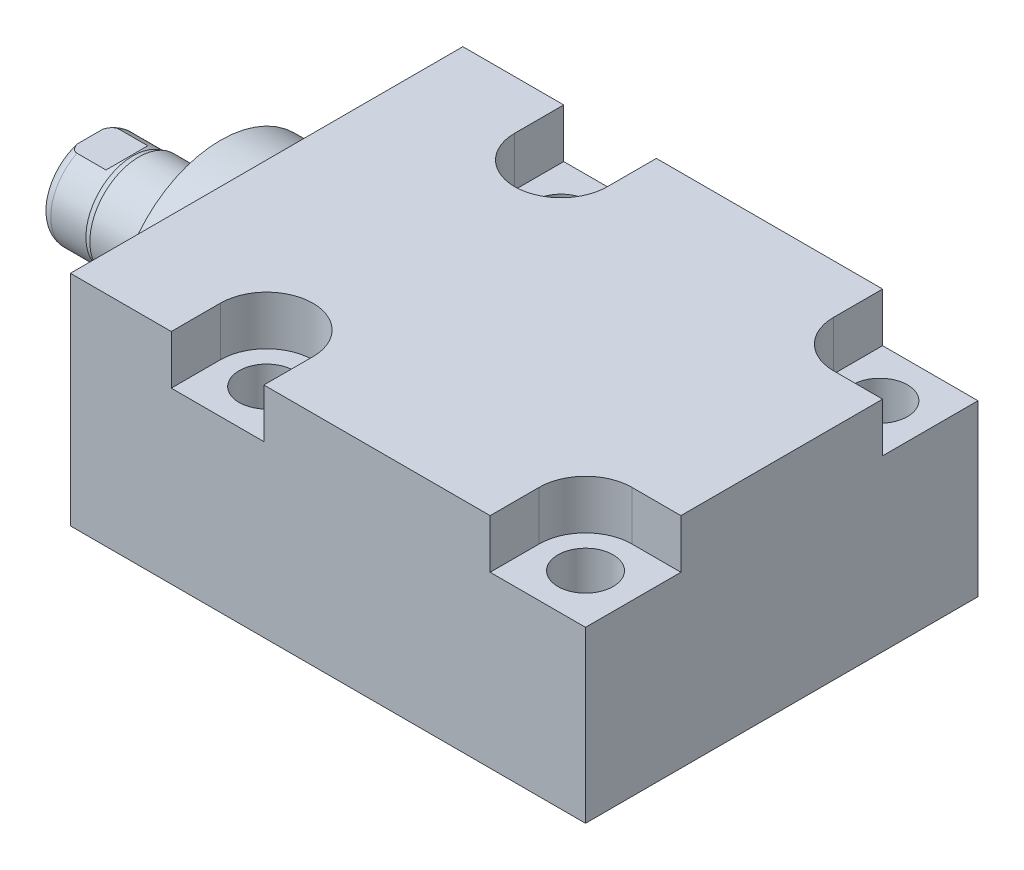
from build123d import *

# Parameters (mm, degrees)
SKETCH1_W          = 50.8
SKETCH1_H          = 28.321
EXTRUDE1_DEPTH     = 66.675
SKETCH5_R          = 13.5001
EXTRUDE2_DEPTH     = 5.969
SKETCH6_W          = 6.35
SKETCH6_H          = 16.891
CUT_EXTRUDE4_DEPTH = 30.48
HOLE2_D            = 7.1374
HOLE2_DEPTH        = 28.321
LPATTERN1_COUNT    = 2
LPATTERN1_PITCH    = 41.275
CUT_EXTRUDE5_DEPTH = 6.35
HOLE3_D            = 2.3876
HOLE3_DEPTH        = 14.224
HOLE3_CBORE_D      = 11.3411
HOLE3_CBORE_DEPTH  = 1.4478
HOLE3_TIP          = 0.717307407
HOLE4_D            = 3.175
HOLE4_DEPTH        = 14.224
HOLE4_TIP          = 0.953866233
SKETCH26_R         = 5.6705
CUT_EXTRUDE6_DEPTH = 1.448
CHAMFER1_SIZE      = 0.635
SKETCH23_R         = 1.4478
LPATTERN3_COUNT    = 2
LPATTERN3_PITCH    = 41.275


with BuildPart() as part:
    # Sketch1 → Extrude1 (new body)
    with BuildSketch(Plane(origin=(0, 0, 0), x_dir=(0, 0, -1), z_dir=(1, 0, 0))):
        with Locations((0, 0.1105)):
            Rectangle(SKETCH1_W, SKETCH1_H)
    extrude(amount=EXTRUDE1_DEPTH)

    # Sketch5 → Extrude2 (add)
    with BuildSketch(Plane.ZY):
        with Locations(Location((0, 0, 0), (0, 0, 180))):  # turned: the seam where the file's is
            Circle(SKETCH5_R)
    extrude(amount=EXTRUDE2_DEPTH)

    # Sketch6 → Revolve1 (revolve)
    with BuildSketch(Plane(origin=(0, 0, 0), x_dir=(0, 0, 1), z_dir=(0, -1, 0))):
        with Locations((-3.175, 14.4145)):
            Rectangle(SKETCH6_W, SKETCH6_H)
    revolve(axis=Axis((5.754582971, 0, 0), (-1, 0, 0)))

    # S2D0001 → Cut-Revolve4 (revolve, cut)
    with BuildSketch(Plane(origin=(-18.511260017, 3.2639, 0), x_dir=(0, 1, 0), z_dir=(0, 0, 1)), mode=Mode.PRIVATE) as cut_revolve4_sk:
        Polygon((-0.7112, 2.786949769), (-0.7112, -11.653260017), (-3.2639, -13.18707692), (-3.2639, 4.348739983), (0.1905, 4.348739983), align=None)
    revolve(cut_revolve4_sk.sketch.rotate(Axis((0, 0, 0), (-1, 0, 0)), 90), axis=Axis((0, 0, 0), (-1, 0, 0)), mode=Mode.SUBTRACT)  # turned: the seam where the file's is

    # Sketch8 → Cut-Revolve5 (revolve, cut)
    with BuildSketch(Plane(origin=(0, 0, 0), x_dir=(0, 0, -1), z_dir=(0, 1, 0)), mode=Mode.PRIVATE) as cut_revolve5_sk:
        with BuildLine():
            Line((-6.35, 16.5354), (-6.096, 17.2974))
            Line((-6.096, 17.2974), (-6.096, 21.844))
            ThreePointArc((-6.096, 21.844), (-5.995678675, 22.387796865), (-5.707922533, 22.86))
            Line((-5.707922533, 22.86), (-6.35, 22.86))
            Line((-6.35, 22.86), (-6.35, 16.5354))
        make_face()
    revolve(cut_revolve5_sk.sketch.rotate(Axis((-12.65936, 0, 0), (-1, 0, 0)), 180), axis=Axis((-12.65936, 0, 0), (-1, 0, 0)), mode=Mode.SUBTRACT)  # turned: the seam where the file's is

    # Sketch12 → Cut-Extrude4 (cut, symmetric)
    with BuildSketch(Plane(origin=(0, 0, 0), x_dir=(0, -1, 0), z_dir=(0, 0, -1))):
        Polygon((5.461, 22.86), (5.461, 18.0848), (6.096, 17.4498), (6.096, 22.86), align=None)
        Polygon((-5.461, 22.86), (-5.461, 18.0848), (-6.096, 17.4498), (-6.096, 22.86), align=None)
    extrude(amount=CUT_EXTRUDE4_DEPTH, both=True, mode=Mode.SUBTRACT)

    # Hole2
    with Locations(Plane(origin=(0, 14.271, 0), x_dir=(-1, 0, 0), z_dir=(0, 1, 0))):
        with Locations((-19.05, -19.05), (-19.05, 19.05)):
            hole2 = Hole(HOLE2_D / 2, depth=HOLE2_DEPTH)

    # LPattern1: Hole2 ×2
    with Locations(*[(i * LPATTERN1_PITCH, 0, 0) for i in range(1, LPATTERN1_COUNT)]):
        add(hole2, mode=Mode.SUBTRACT)

    # Sketch18 → Cut-Extrude5 (cut)
    with BuildSketch(Plane(origin=(0, 14.271, 0), x_dir=(1, 0, 0), z_dir=(0, 1, 0))):
        with BuildLine():
            Line((66.675, -25.4), (54.3306, -25.4))
            Line((54.3306, -25.4), (54.3306, -19.05))
            ThreePointArc((54.3306, -19.05), (56.086319111, -14.811319111), (60.325, -13.0556))
            Line((60.325, -13.0556), (66.675, -13.0556))
            Line((66.675, -13.0556), (66.675, -25.4))
        make_face()
        with BuildLine():
            Line((13.0556, -19.05), (13.0556, -25.4))
            Line((13.0556, -25.4), (25.0444, -25.4))
            Line((25.0444, -25.4), (25.0444, -19.05))
            ThreePointArc((25.0444, -19.05), (19.05, -13.0556), (13.0556, -19.05))
        make_face()
        with BuildLine():
            Line((66.675, 13.0556), (66.675, 25.4))
            Line((66.675, 25.4), (54.3306, 25.4))
            Line((54.3306, 25.4), (54.3306, 19.05))
            ThreePointArc((54.3306, 19.05), (56.086319111, 14.811319111), (60.325, 13.0556))
            Line((60.325, 13.0556), (66.675, 13.0556))
        make_face()
        with BuildLine():
            Line((25.0444, 25.4), (13.0556, 25.4))
            Line((13.0556, 25.4), (13.0556, 19.05))
            ThreePointArc((13.0556, 19.05), (19.05, 13.0556), (25.0444, 19.05))
            Line((25.0444, 19.05), (25.0444, 25.4))
        make_face()
    extrude(amount=-CUT_EXTRUDE5_DEPTH, mode=Mode.SUBTRACT)

    # Hole3
    with Locations(Plane.XZ.offset(14.05)):
        with Locations((12.7, 0)):
            CounterBoreHole(HOLE3_D / 2, HOLE3_CBORE_D / 2, HOLE3_CBORE_DEPTH, depth=HOLE3_DEPTH)
            with Locations((0, 0, -(HOLE3_DEPTH + HOLE3_TIP / 2))):  # 118° drill point
                Cone(0, HOLE3_D / 2, HOLE3_TIP, mode=Mode.SUBTRACT)

    # Hole4
    with Locations(Plane.XZ.offset(14.05)):
        with Locations((55.425, 0)):
            Hole(HOLE4_D / 2, depth=HOLE4_DEPTH)
            with Locations((0, 0, -(HOLE4_DEPTH + HOLE4_TIP / 2))):  # 118° drill point
                Cone(0, HOLE4_D / 2, HOLE4_TIP, mode=Mode.SUBTRACT)

    # Sketch26 → Cut-Extrude6 (cut)
    with BuildSketch(Plane.XZ.offset(14.05)):
        with Locations(Location((53.975, 0, 0), (0, 0, 270))):  # turned: the seam where the file's is
            Circle(SKETCH26_R)
    extrude(amount=-CUT_EXTRUDE6_DEPTH, mode=Mode.SUBTRACT)

    # Chamfer1
    chamfer1_edges = [part.edges().sort_by_distance(p)[0] for p in [
        (13.8938, -12.6022, 0),
        (57.0125, -12.602, 0),
    ]]
    chamfer(chamfer1_edges, length=CHAMFER1_SIZE)


with BuildPart() as body_2:
    # Sketch23 → Revolve2 (revolve)
    with BuildSketch(Plane.XY, mode=Mode.PRIVATE) as revolve2_sk:
        with Locations((8.47725, -14.05)):
            Circle(SKETCH23_R)
    revolve(revolve2_sk.sketch.rotate(Axis((12.7, -12.6022, 0), (0, -1, 0)), 90), axis=Axis((12.7, -12.6022, 0), (0, -1, 0)))  # turned: the seam where the file's is


with BuildPart() as lpattern3_1:
    # LPattern3: pattern copy
    add(body_2.part.moved(Location(Vector(1, 0, 0) * (1 * LPATTERN3_PITCH))))


solid = Compound([part.part, body_2.part, lpattern3_1.part])
